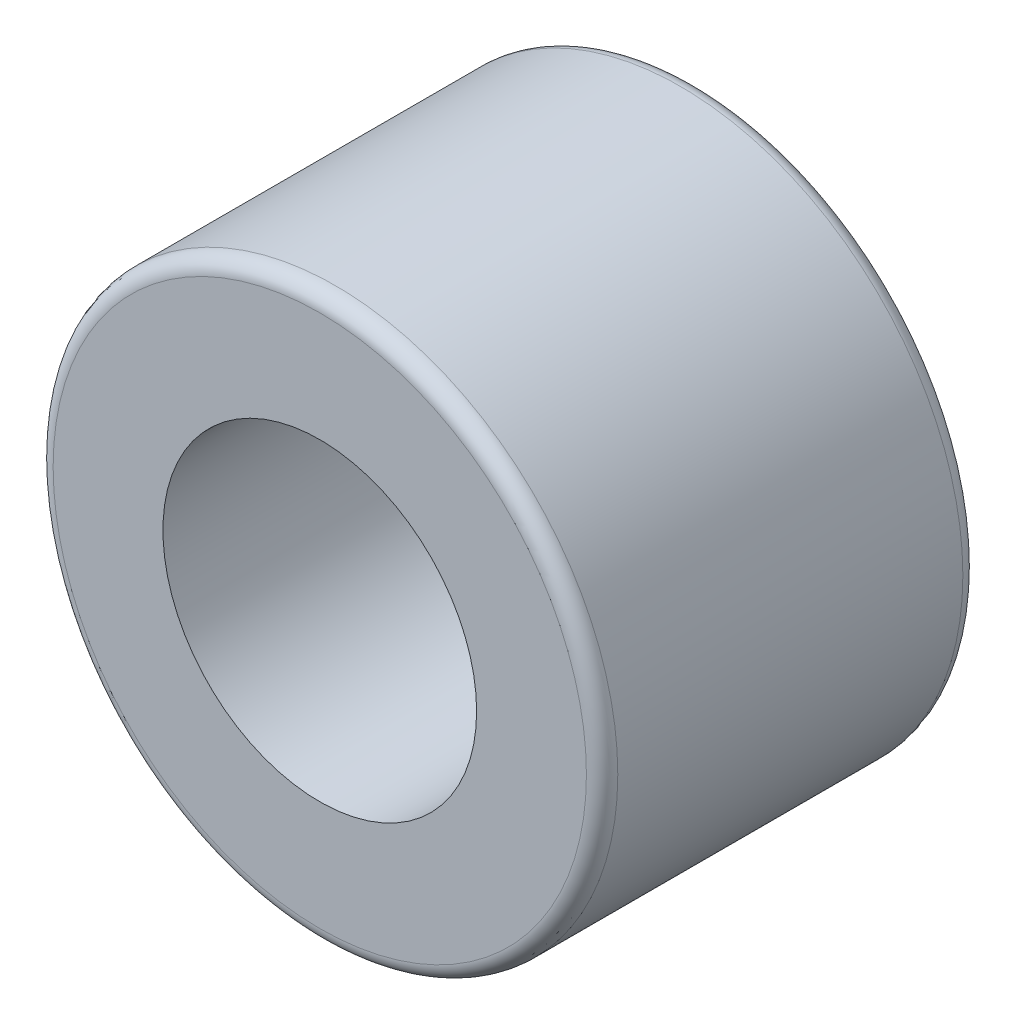
from build123d import *

# Parameters (mm, degrees)
SKETCH1_R      = 14.2875
SKETCH1_R_2    = 7.9375
EXTRUDE1_DEPTH = 9.525
FILLET1_R      = 0.79375


with BuildPart() as part:
    # Sketch1 → Extrude1 (new body, symmetric)
    with BuildSketch(Plane.XY):
        Circle(SKETCH1_R)
        Circle(SKETCH1_R_2, mode=Mode.SUBTRACT)
    extrude(amount=EXTRUDE1_DEPTH, both=True)

    # Fillet1
    fillet1_edges = [part.edges().sort_by_distance(p)[0] for p in [
        (-14.2875, 0, -9.525),
        (-14.2875, 0, 9.525),
    ]]
    fillet(fillet1_edges, radius=FILLET1_R)


solid = part.part
